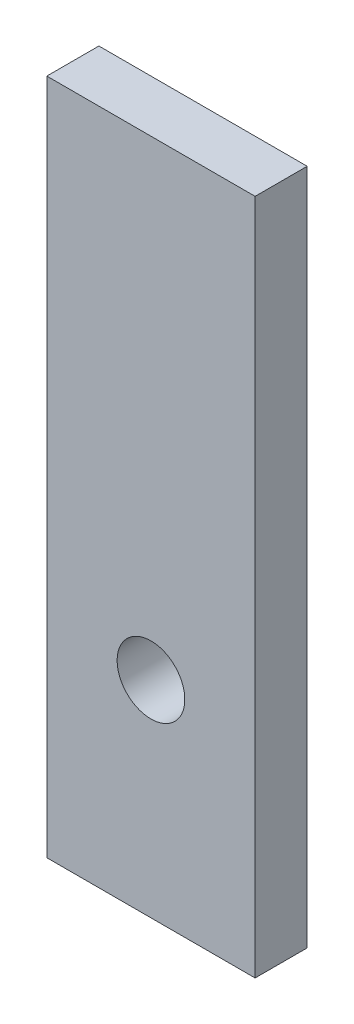
from build123d import *

# Parameters (mm, degrees)
SKETCH1_W           = 5.08
SKETCH1_H           = 16.51
BOSS_EXTRUDE1_DEPTH = 1.27
SKETCH2_R           = 0.8255
CUT_EXTRUDE1_DEPTH  = 2.54


with BuildPart() as part:
    # Sketch1 → Boss-Extrude1 (new body)
    with BuildSketch(Plane.XY):
        with Locations((-5.547911289, -27.250393807)):
            Rectangle(SKETCH1_W, SKETCH1_H)
    extrude(amount=BOSS_EXTRUDE1_DEPTH)

    # Sketch2 → Cut-Extrude1 (cut)
    with BuildSketch(Plane(origin=(0, 0, 0), x_dir=(-1, 0, 0), z_dir=(0, 0, -1))):
        with Locations((5.547911289, -30.48)):
            Circle(SKETCH2_R)
    extrude(amount=-CUT_EXTRUDE1_DEPTH, mode=Mode.SUBTRACT)


solid = part.part
